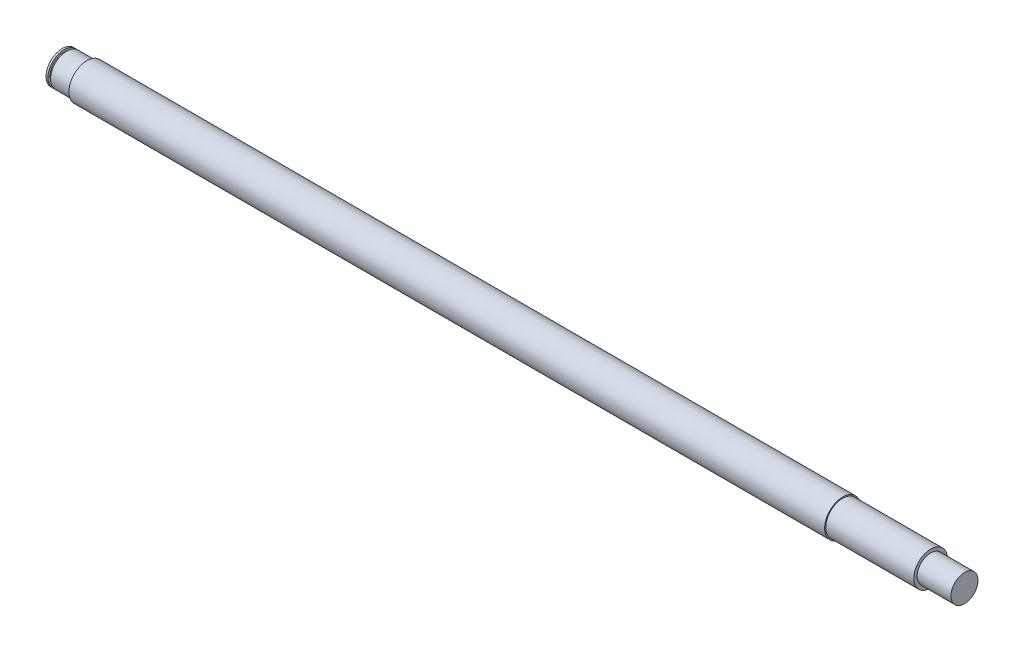
from build123d import *


with BuildPart() as part:
    # 草图1 → 旋转1 (revolve)
    with BuildSketch(Plane.XY):
        Polygon((0, 0), (0, 7.15), (0.85, 7.15), (0.85, 6.15), (2, 6.15), (2, 7.15), (11, 7.15), (11, 8), (346, 8), (346, 7.5), (385, 7.5), (385, 6), (400, 6), (400, 0), align=None)
    revolve(axis=Axis((-271.922806095, 0, 0), (1, 0, 0)))


solid = part.part
